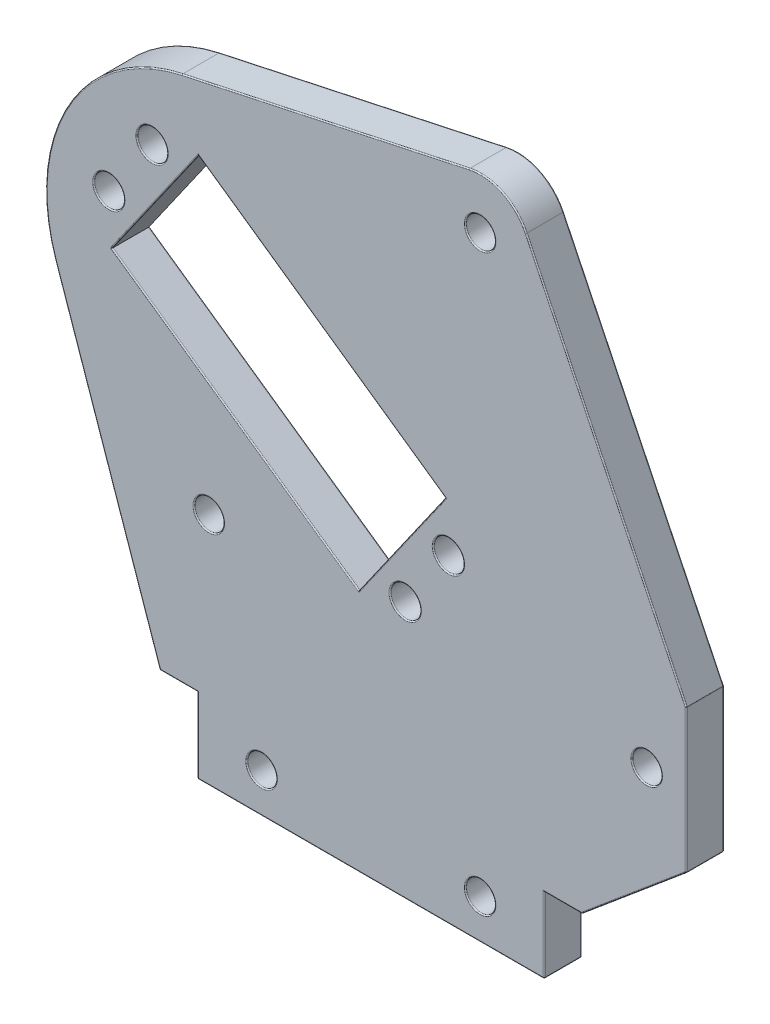
from build123d import *

# Parameters (mm, degrees)
SKETCH2_R           = 2
SKETCH2_R_2         = 1.95
BOSS_EXTRUDE2_DEPTH = 5
FILLET1_R           = 0.15


with BuildPart() as part:
    # Sketch2 → Boss-Extrude2 (new body)
    with BuildSketch(Plane.XY):
        with BuildLine():
            Line((-23, 0), (-23, 10))
            Line((-23, 10), (-28, 10))
            Line((-28, 10), (-41.843761624, 50.118193368))
            ThreePointArc((-41.843761624, 50.118193368), (-40.146654928, 68.813612437), (-25.029728066, 79.943634341))
            Line((-25.029728066, 79.943634341), (13.072325527, 88.138211024))
            ThreePointArc((13.072325527, 88.138211024), (17.477220077, 87.602479874), (20.610605748, 84.460506273))
            Line((20.610605748, 84.460506273), (41.85, 40.621529892))
            Line((41.85, 40.621529892), (41.85, 21.621529892))
            Line((41.85, 21.621529892), (28, 10))
            Line((28, 10), (23, 10))
            Line((23, 10), (23, 0))
            Line((23, 0), (-23, 0))
        make_face()
        with Locations((-29.025034449, 69.849224439)):
            Circle(SKETCH2_R, mode=Mode.SUBTRACT)
        with Locations((-34.760798813, 61.657703997)):
            Circle(SKETCH2_R, mode=Mode.SUBTRACT)
        with Locations((10.294263677, 42.317555495)):
            Circle(SKETCH2_R, mode=Mode.SUBTRACT)
        with Locations((4.558499313, 34.126035052)):
            Circle(SKETCH2_R, mode=Mode.SUBTRACT)
        with Locations((14.5, 81.5)):
            Circle(SKETCH2_R_2, mode=Mode.SUBTRACT)
        with Locations((36.6, 31.121529892)):
            Circle(SKETCH2_R_2, mode=Mode.SUBTRACT)
        with Locations((14.5, 5.25)):
            Circle(SKETCH2_R_2, mode=Mode.SUBTRACT)
        with Locations((-14.5, 5.25)):
            Circle(SKETCH2_R_2, mode=Mode.SUBTRACT)
        with Locations((-21.5, 31.121529892)):
            Circle(SKETCH2_R_2, mode=Mode.SUBTRACT)
        Polygon((-22.88054409, 71.650678915), (-34.352072817, 55.26763803), (-1.585991046, 32.324580576), (9.885537681, 48.707621461), align=None, mode=Mode.SUBTRACT)
    extrude(amount=-BOSS_EXTRUDE2_DEPTH)

    # Fillet1
    fillet1_edges = [part.edges().sort_by_distance(p)[0] for p in [
        (-23, 5, 0),
        (-25.5, 10, 0),
        (25.5, 10, -5),
        (-34.921880812, 30.059096684, 0),
        (-40.146654928, 68.813612437, 0),
        (-5.978701269, 84.040922682, 0),
        (17.477220077, 87.602479874, 0),
        (31.230302874, 62.541018083, 0),
        (41.85, 31.121529892, 0),
        (34.925, 15.810764946, 0),
        (25.5, 10, 0),
        (23, 5, 0),
        (0, 0, 0),
        (34.925, 15.810764946, -5),
        (-23, 0, -2.5),
        (-28, 10, -2.5),
        (41.85, 31.121529892, -5),
        (41.85, 40.621529892, -2.5),
        (41.85, 21.621529892, -2.5),
        (28, 10, -2.5),
        (23, 0, -2.5),
        (31.230302874, 62.541018083, -5),
        (17.477220077, 87.602479874, -5),
        (-5.978701269, 84.040922682, -5),
        (-6.497503205, 60.179150188, -5),
        (4.149773318, 40.516101019, -5),
        (-17.969031932, 43.796109303, -5),
        (-28.616308454, 63.459158473, -5),
        (-6.497503205, 60.179150188, 0),
        (-28.616308454, 63.459158473, 0),
        (-17.969031932, 43.796109303, 0),
        (4.149773318, 40.516101019, 0),
        (-40.146654928, 68.813612437, -5),
        (-34.921880812, 30.059096684, -5),
        (-31.025034449, 69.849224439, -5),
        (-31.025034449, 69.849224439, 0),
        (-25.5, 10, -5),
        (-36.760798813, 61.657703997, -5),
        (-36.760798813, 61.657703997, 0),
        (-23, 5, -5),
        (0, 0, -5),
        (8.294263677, 42.317555495, -5),
        (8.294263677, 42.317555495, 0),
        (2.558499313, 34.126035052, -5),
        (2.558499313, 34.126035052, 0),
        (12.55, 81.5, -5),
        (12.55, 81.5, 0),
        (34.65, 31.121529892, -5),
        (34.65, 31.121529892, 0),
        (12.55, 5.25, -5),
        (12.55, 5.25, 0),
        (-16.45, 5.25, -5),
        (-16.45, 5.25, 0),
        (-23.45, 31.121529892, -5),
        (-23.45, 31.121529892, 0),
        (23, 5, -5),
    ]]
    fillet(fillet1_edges, radius=FILLET1_R)


solid = part.part
